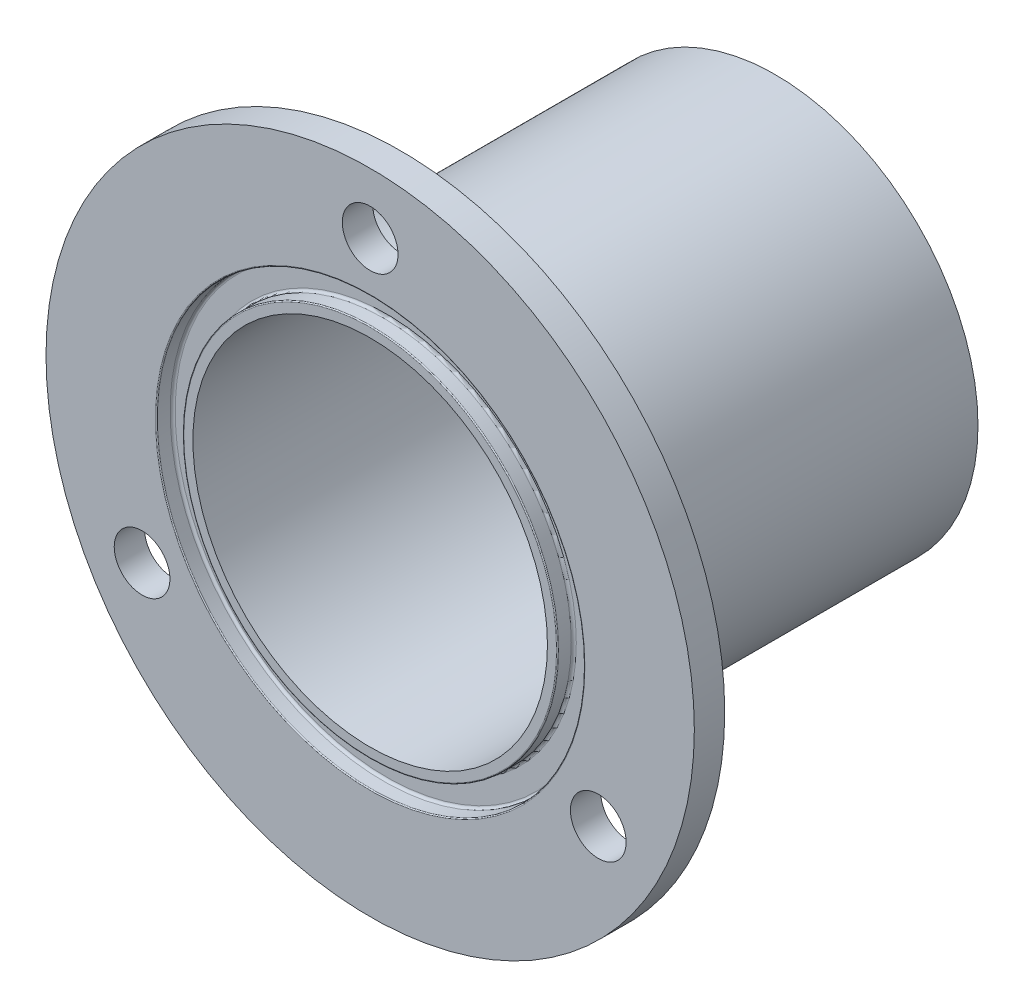
from build123d import *

# Parameters (mm, degrees)
SKETCH1_R           = 20
SKETCH1_R_2         = 17.5
BOSS_EXTRUDE1_DEPTH = 20
SKETCH2_R           = 32
SKETCH2_R_2         = 20
BOSS_EXTRUDE2_DEPTH = 3
SKETCH4_W           = 2.75
SKETCH4_H           = 3
CIRPATTERN1_COUNT   = 3
CHAMFER1_SIZE       = 1
SKETCH5_R           = 21.1
SKETCH5_R_2         = 18.5
CUT_EXTRUDE1_DEPTH  = 1.6
FILLET1_R           = 0.25
FILLET2_R           = 0.1
FILLET3_R           = 1


with BuildPart() as part:
    # Sketch1 → Boss-Extrude1 (new body, symmetric)
    with BuildSketch(Plane.XY):
        Circle(SKETCH1_R)
        Circle(SKETCH1_R_2, mode=Mode.SUBTRACT)
    extrude(amount=BOSS_EXTRUDE1_DEPTH, both=True)

    # Chamfer1
    chamfer1_edges = [part.edges().sort_by_distance(p)[0] for p in [
        (-17.5, 0, -20),
    ]]
    chamfer(chamfer1_edges, length=CHAMFER1_SIZE)


with BuildPart() as body_2:
    # Sketch2 → Boss-Extrude2 (new body)
    with BuildSketch(Plane.XY.offset(20)):
        Circle(SKETCH2_R)
        Circle(SKETCH2_R_2, mode=Mode.SUBTRACT)
    extrude(amount=-BOSS_EXTRUDE2_DEPTH)

    # Sketch4 → M5 Clearance Hole1 (revolve, cut)
    with BuildSketch(Plane(origin=(0, 26, 17), x_dir=(0, 1, 0), z_dir=(1, 0, 0))):
        with Locations((1.375, 1.5)):
            Rectangle(SKETCH4_W, SKETCH4_H)
    m5_clearance_hole1 = revolve(axis=Axis((0, 26, 10.65), (0, 0, 1)), mode=Mode.SUBTRACT)

    # CirPattern1: M5 Clearance Hole1 ×3 about axis
    cirpattern1_axis = Axis((0, 0, 0), (0, 0, 1))
    for i in range(1, CIRPATTERN1_COUNT):
        add(m5_clearance_hole1.rotate(cirpattern1_axis, i * 360 / CIRPATTERN1_COUNT), mode=Mode.SUBTRACT)


with BuildPart() as part_1:
    add(part.part)

    # Combine1: union body 2
    add(body_2.part)

    # Sketch5 → Cut-Extrude1 (cut)
    with BuildSketch(Plane.XY.offset(20)):
        Circle(SKETCH5_R)
        Circle(SKETCH5_R_2, mode=Mode.SUBTRACT)
    extrude(amount=-CUT_EXTRUDE1_DEPTH, mode=Mode.SUBTRACT)

    # Fillet1
    fillet1_edges = [part_1.edges().sort_by_distance(p)[0] for p in [
        (-21.1, 0, 18.4),
        (-18.5, 0, 18.4),
    ]]
    fillet(fillet1_edges, radius=FILLET1_R)

    # Fillet2
    fillet2_edges = [part_1.edges().sort_by_distance(p)[0] for p in [
        (-21.1, 0, 20),
        (-18.5, 0, 20),
    ]]
    fillet(fillet2_edges, radius=FILLET2_R)

    # Fillet3
    fillet3_edges = [part_1.edges().sort_by_distance(p)[0] for p in [
        (-20, 0, 17),
    ]]
    fillet(fillet3_edges, radius=FILLET3_R)


solid = part_1.part
